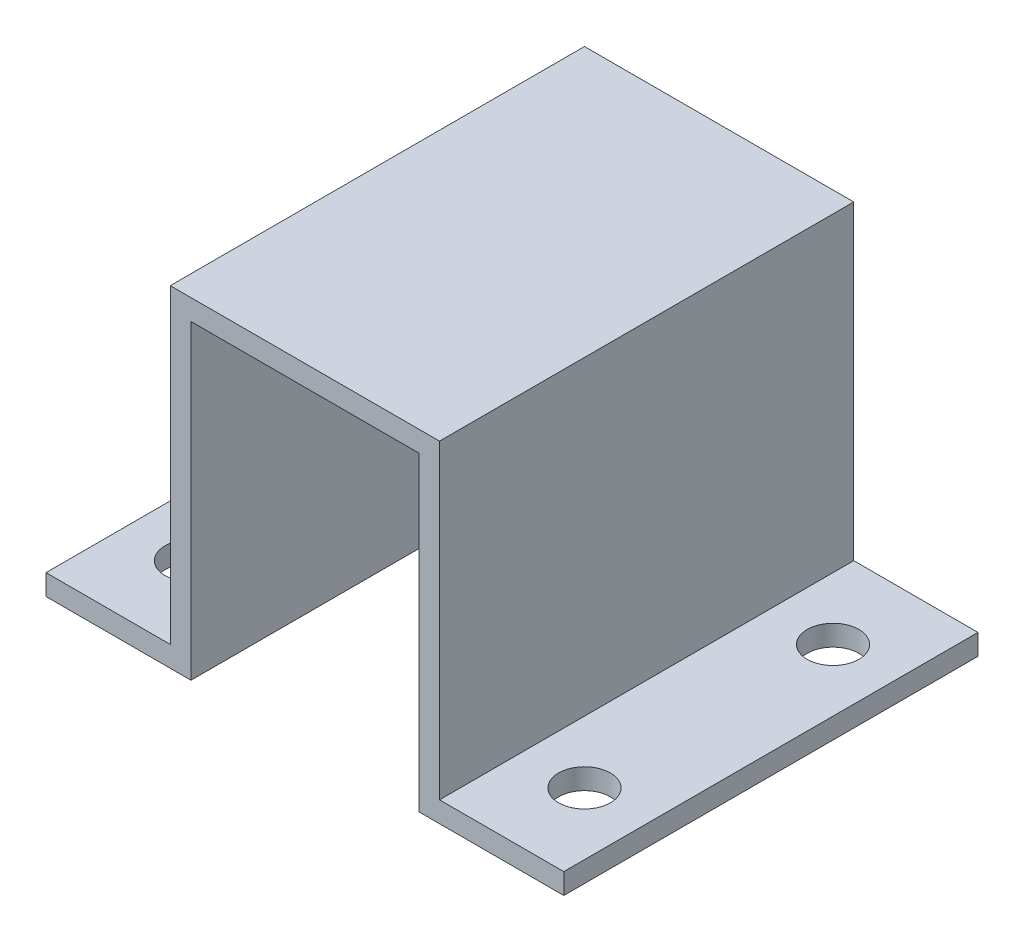
from build123d import *

# Parameters (mm, degrees)
BOSS_EXTRUDE3_DEPTH = 50.8
CUT_EXTRUDE1_REACH  = 4.54
SKETCH6_R           = 3.175


with BuildPart() as part:
    # Sketch5 → Boss-Extrude3 (new body)
    with BuildSketch(Plane.XY):
        Polygon((0, 0), (17.78, 0), (17.78, 38.1), (31.75, 38.1), (31.75, 40.64), (15.24, 40.64), (15.24, 2.54), (0, 2.54), align=None)
    boss_extrude3 = extrude(amount=BOSS_EXTRUDE3_DEPTH)

    # Mirror6: Boss-Extrude3 across plane
    add(boss_extrude3.mirror(Plane(origin=(31.75, 40.64, 50.8), x_dir=(0, 0, 1), z_dir=(-1, 0, 0))))

    # Sketch6 → Cut-Extrude1 (cut, up to next)
    with BuildSketch(Plane(origin=(0, 2.54, 0), x_dir=(-1, 0, 0), z_dir=(0, 1, 0)), mode=Mode.PRIVATE) as cut_extrude1_sk1:
        with Locations((-7.62, 40.64)):
            Circle(SKETCH6_R)
    cut_extrude1_tool1 = extrude(cut_extrude1_sk1.sketch, amount=-CUT_EXTRUDE1_REACH, mode=Mode.PRIVATE) & part.part
    add(cut_extrude1_tool1.solids().sort_by_distance((7.62, 2.54, 40.64))[0], mode=Mode.SUBTRACT)
    # Sketch6 → Cut-Extrude1 (cut, up to next)
    with BuildSketch(Plane(origin=(0, 2.54, 0), x_dir=(-1, 0, 0), z_dir=(0, 1, 0)), mode=Mode.PRIVATE) as cut_extrude1_sk2:
        with Locations((-7.62, 10.16)):
            Circle(SKETCH6_R)
    cut_extrude1_tool2 = extrude(cut_extrude1_sk2.sketch, amount=-CUT_EXTRUDE1_REACH, mode=Mode.PRIVATE) & part.part
    add(cut_extrude1_tool2.solids().sort_by_distance((7.62, 2.54, 10.16))[0], mode=Mode.SUBTRACT)
    # Sketch6 → Cut-Extrude1 (cut, up to next)
    with BuildSketch(Plane(origin=(0, 2.54, 0), x_dir=(-1, 0, 0), z_dir=(0, 1, 0)), mode=Mode.PRIVATE) as cut_extrude1_sk3:
        with Locations((-55.88, 10.16)):
            Circle(SKETCH6_R)
    cut_extrude1_tool3 = extrude(cut_extrude1_sk3.sketch, amount=-CUT_EXTRUDE1_REACH, mode=Mode.PRIVATE) & part.part
    add(cut_extrude1_tool3.solids().sort_by_distance((55.88, 2.54, 10.16))[0], mode=Mode.SUBTRACT)
    # Sketch6 → Cut-Extrude1 (cut, up to next)
    with BuildSketch(Plane(origin=(0, 2.54, 0), x_dir=(-1, 0, 0), z_dir=(0, 1, 0)), mode=Mode.PRIVATE) as cut_extrude1_sk4:
        with Locations((-55.88, 40.64)):
            Circle(SKETCH6_R)
    cut_extrude1_tool4 = extrude(cut_extrude1_sk4.sketch, amount=-CUT_EXTRUDE1_REACH, mode=Mode.PRIVATE) & part.part
    add(cut_extrude1_tool4.solids().sort_by_distance((55.88, 2.54, 40.64))[0], mode=Mode.SUBTRACT)


solid = part.part
